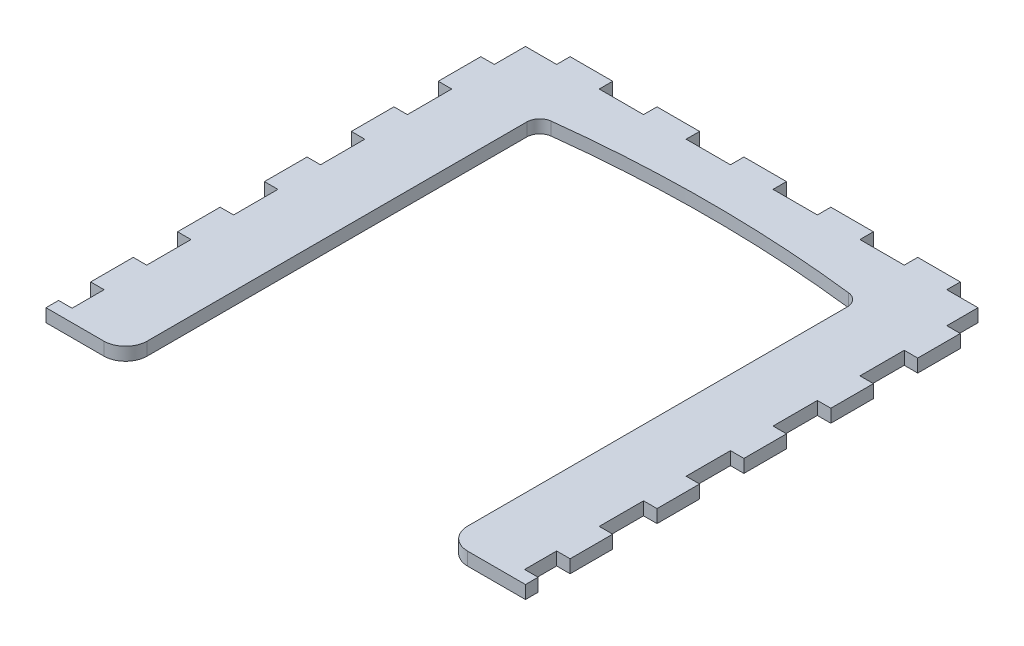
from build123d import *

# Parameters (mm, degrees)
BOSS_EXTRUDE1_DEPTH = 3
SKETCH2_W           = 3.2
SKETCH2_H           = 7.372217102
SKETCH2_H_2         = 10.2
SKETCH2_W_2         = 10.2
SKETCH2_H_3         = 3.2
CUT_EXTRUDE1_DEPTH  = 4


with BuildPart() as part:
    # Sketch1 → Boss-Extrude1 (new body)
    with BuildSketch(Plane(origin=(0, 0, 0), x_dir=(1, 0, 0), z_dir=(0, 1, 0))):
        with BuildLine():
            Line((55.172217102, -43.501443346), (55.172217102, 66.842990858))
            Line((55.172217102, 66.842990858), (-55.172217102, 66.842990858))
            Line((-55.172217102, 66.842990858), (-55.172217102, -43.501443346))
            Line((-55.172217102, -43.501443346), (-41.872217102, -43.501443346))
            ThreePointArc((-41.872217102, -43.501443346), (-38.336683196, -42.036977252), (-36.872217102, -38.501443346))
            Line((-36.872217102, -38.501443346), (-36.872217102, 48.842990858))
            ThreePointArc((-36.872217102, 48.842990858), (-36.114885762, 50.835586471), (-34.225258916, 51.822145348))
            ThreePointArc((-34.225258916, 51.822145348), (0, 53.842990858), (34.225258916, 51.822145348))
            ThreePointArc((34.225258916, 51.822145348), (36.114885762, 50.835586471), (36.872217102, 48.842990858))
            Line((36.872217102, 48.842990858), (36.872217102, -38.501443346))
            ThreePointArc((36.872217102, -38.501443346), (38.336683196, -42.036977252), (41.872217102, -43.501443346))
            Line((41.872217102, -43.501443346), (55.172217102, -43.501443346))
        make_face()
    extrude(amount=BOSS_EXTRUDE1_DEPTH)

    # Sketch2 → Cut-Extrude1 (cut, through all)
    with BuildSketch(Plane(origin=(0, 0, 0), x_dir=(1, 0, 0), z_dir=(0, 1, 0))):
        with Locations((-53.672217102, -36.915334795)):
            Rectangle(SKETCH2_W, SKETCH2_H)
        Polygon((-44.9, 63.742990858), (-44.9, 66.942990858), (-55.272217102, 66.942990858), (-55.272217102, 56.570773756), (-52.072217102, 56.570773756), (-52.072217102, 63.742990858), align=None)
        with Locations((-53.672217102, 1.670773756)):
            Rectangle(SKETCH2_W, SKETCH2_H_2)
        with Locations((-53.672217102, -18.329226244)):
            Rectangle(SKETCH2_W, SKETCH2_H_2)
        with Locations((-53.672217102, 21.670773756)):
            Rectangle(SKETCH2_W, SKETCH2_H_2)
        with Locations((-53.672217102, 41.670773756)):
            Rectangle(SKETCH2_W, SKETCH2_H_2)
        with Locations((-30, 65.342990858)):
            Rectangle(SKETCH2_W_2, SKETCH2_H_3)
        with Locations((-10, 65.342990858)):
            Rectangle(SKETCH2_W_2, SKETCH2_H_3)
        with Locations((53.672217102, 41.670773756)):
            Rectangle(SKETCH2_W, SKETCH2_H_2)
        with Locations((53.672217102, 21.670773756)):
            Rectangle(SKETCH2_W, SKETCH2_H_2)
        with Locations((53.672217102, 1.670773756)):
            Rectangle(SKETCH2_W, SKETCH2_H_2)
        with Locations((53.672217102, -18.329226244)):
            Rectangle(SKETCH2_W, SKETCH2_H_2)
        with Locations((53.672217102, -36.915334795)):
            Rectangle(SKETCH2_W, SKETCH2_H)
        with Locations((30, 65.342990858)):
            Rectangle(SKETCH2_W_2, SKETCH2_H_3)
        with Locations((10, 65.342990858)):
            Rectangle(SKETCH2_W_2, SKETCH2_H_3)
        Polygon((44.9, 66.942990858), (55.272217102, 66.942990858), (55.272217102, 56.570773756), (52.072217102, 56.570773756), (52.072217102, 63.742990858), (44.9, 63.742990858), align=None)
    extrude(amount=CUT_EXTRUDE1_DEPTH, mode=Mode.SUBTRACT)


solid = part.part
